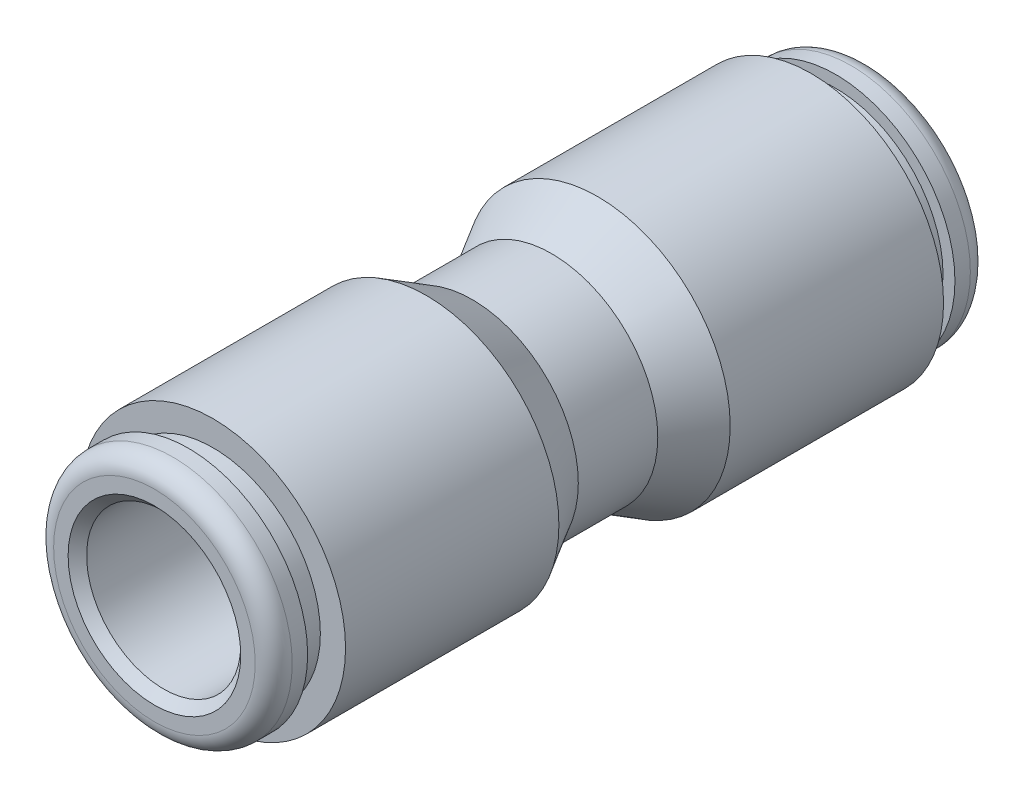
from build123d import *

# Parameters (mm, degrees)
SKETCH9_R      = 3.175
SKETCH9_R_2    = 2.413
EXTRUDE1_DEPTH = 1.016


with BuildPart() as part:
    # Sketch8 → Revolve1 (revolve)
    with BuildSketch(Plane(origin=(0, 0, 0), x_dir=(0, 0, -1), z_dir=(1, 0, 0)), mode=Mode.PRIVATE) as revolve1_sk:
        with BuildLine():
            Line((13.335, 4.9149), (13.97, 4.9149))
            ThreePointArc((13.97, 4.9149), (14.508815367, 4.691715367), (14.732, 4.1529))
            Line((14.732, 4.1529), (14.732, 3.556))
            Line((14.732, 3.556), (14.351, 3.175))
            Line((14.351, 3.175), (0, 3.175))
            Line((0, 3.175), (0, 4.3688))
            Line((0, 4.3688), (1.636888889, 4.3688))
            Line((1.636888889, 4.3688), (3.528634781, 5.461))
            Line((3.528634781, 5.461), (12.319, 5.461))
            Line((12.319, 5.461), (12.319, 4.42341))
            Line((12.319, 4.42341), (13.335, 4.42341))
            Line((13.335, 4.42341), (13.335, 4.9149))
        make_face()
    revolve1 = revolve(revolve1_sk.sketch.rotate(Axis((0, 0, 0), (0, 0, -1)), 90), axis=Axis((0, 0, 0), (0, 0, -1)))  # turned: the seam where the file's is

    # Sketch9 → Extrude1 (add)
    with BuildSketch(Plane.XY):
        Circle(SKETCH9_R)
        Circle(SKETCH9_R_2, mode=Mode.SUBTRACT)
    extrude(amount=-EXTRUDE1_DEPTH)

    # Mirror1: Revolve1 across plane
    add(revolve1.mirror(Plane.XY))


solid = part.part
